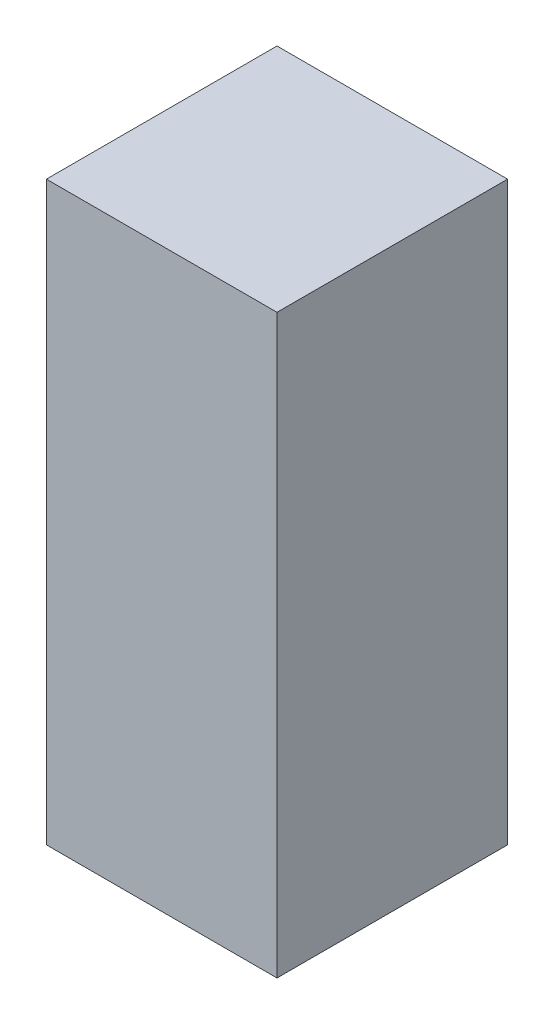
from build123d import *

# Parameters (mm, degrees)
SKETCH1_W           = 4
SKETCH1_H           = 4
BOSS_EXTRUDE1_DEPTH = 10


with BuildPart() as part:
    # Sketch1 → Boss-Extrude1 (new body)
    with BuildSketch(Plane(origin=(0, 0, 0), x_dir=(1, 0, 0), z_dir=(0, 1, 0))):
        with Locations((2, 2)):
            Rectangle(SKETCH1_W, SKETCH1_H)
    extrude(amount=BOSS_EXTRUDE1_DEPTH)


solid = part.part
